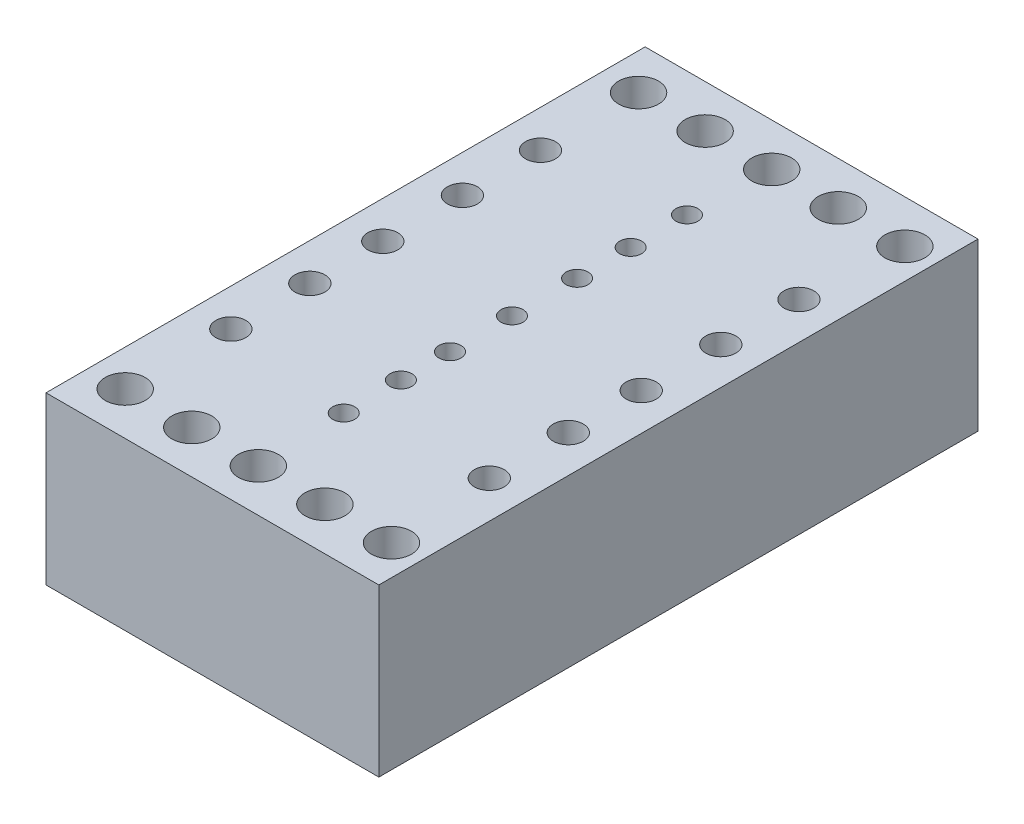
from build123d import *

# Parameters (mm, degrees)
CROQUIS1_W                            = 100
CROQUIS1_H                            = 180
SALIENTE_EXTRUIR1_DEPTH               = 50
TALADRO1_D                            = 12
MATRIZL1_COUNT                        = 5
MATRIZL1_PITCH                        = 20
SIMETR_A1_COPY_1_D                    = 12
SIMETR_A1_COPY_2_D                    = 12
SIMETR_A1_COPY_3_D                    = 12
SIMETR_A1_COPY_4_D                    = 12
TALADRO_DE_MARGEN_PARA_M81_AT_2_COUNT = 2
TALADRO_DE_MARGEN_PARA_M81_AT_2_PITCH = 47.379647221
TALADRO_DE_MARGEN_PARA_M81_AT_3_COUNT = 2
TALADRO_DE_MARGEN_PARA_M81_AT_3_PITCH = 93.023747334
TALADRO_DE_MARGEN_PARA_M81_AT_4_COUNT = 2
TALADRO_DE_MARGEN_PARA_M81_AT_4_PITCH = 23.460534518
TALADRO_DE_MARGEN_PARA_M81_AT_5_COUNT = 2
TALADRO_DE_MARGEN_PARA_M81_AT_5_PITCH = 69.290415903
TALADRO_DE_MARGEN_PARA_M61_D          = 6.6
TALADRO_DE_MARGEN_PARA_M61_DEPTH      = 40
TALADRO_DE_MARGEN_PARA_M61_TIP        = 1.982840043


with BuildPart() as part:
    # Croquis1 → Saliente-Extruir1 (new body)
    with BuildSketch(Plane(origin=(0, 0, 0), x_dir=(1, 0, 0), z_dir=(0, 1, 0))):
        Rectangle(CROQUIS1_W, CROQUIS1_H)
    extrude(amount=SALIENTE_EXTRUIR1_DEPTH)

    # Taladro1 (through all)
    with Locations(Plane(origin=(0, 50, 0), x_dir=(1, 0, 0), z_dir=(0, 1, 0))):
        with Locations((-39.09229064, 77.114510738)):
            taladro1 = Hole(TALADRO1_D / 2)

    # MatrizL1: Taladro1 ×5
    with Locations(*[(i * MATRIZL1_PITCH, 0, 0) for i in range(1, MATRIZL1_COUNT)]):
        add(taladro1, mode=Mode.SUBTRACT)

    # Simetría1: Taladro1 across plane
    add(taladro1.mirror(Plane.XY), mode=Mode.SUBTRACT)

    # Simetría1 copy 1 (through all)
    with Locations(Plane(origin=(20, 50, 0), x_dir=(1, 0, 0), z_dir=(0, 1, 0))):
        with Locations((-39.09229064, -77.114510738)):
            Hole(SIMETR_A1_COPY_1_D / 2)

    # Simetría1 copy 2 (through all)
    with Locations(Plane(origin=(40, 50, 0), x_dir=(1, 0, 0), z_dir=(0, 1, 0))):
        with Locations((-39.09229064, -77.114510738)):
            Hole(SIMETR_A1_COPY_2_D / 2)

    # Simetría1 copy 3 (through all)
    with Locations(Plane(origin=(60, 50, 0), x_dir=(1, 0, 0), z_dir=(0, 1, 0))):
        with Locations((-39.09229064, -77.114510738)):
            Hole(SIMETR_A1_COPY_3_D / 2)

    # Simetría1 copy 4 (through all)
    with Locations(Plane(origin=(80, 50, 0), x_dir=(1, 0, 0), z_dir=(0, 1, 0))):
        with Locations((-39.09229064, -77.114510738)):
            Hole(SIMETR_A1_COPY_4_D / 2)

    # Croquis6 → Taladro de margen para M81 (revolve, cut)
    with BuildSketch(Plane(origin=(-38.819493727, 50, -47.379647221), x_dir=(0, 0, 1), z_dir=(1, 0, 0))):
        Polygon((0, 0), (0, 28.103872786), (4.5, 25.4), (4.5, 0), align=None)
    taladro_de_margen_para_m81 = revolve(axis=Axis((-38.819493727, 56.35, -47.379647221), (0, -1, 0)), mode=Mode.SUBTRACT)

    # Taladro de margen para M81 at 2: Taladro de margen para M81 ×2
    with Locations(*[(0, 0, i * TALADRO_DE_MARGEN_PARA_M81_AT_2_PITCH) for i in range(1, TALADRO_DE_MARGEN_PARA_M81_AT_2_COUNT)]):
        add(taladro_de_margen_para_m81, mode=Mode.SUBTRACT)

    # Taladro de margen para M81 at 3: Taladro de margen para M81 ×2
    with Locations(*[(0, 0, i * TALADRO_DE_MARGEN_PARA_M81_AT_3_PITCH) for i in range(1, TALADRO_DE_MARGEN_PARA_M81_AT_3_COUNT)]):
        add(taladro_de_margen_para_m81, mode=Mode.SUBTRACT)

    # Taladro de margen para M81 at 4: Taladro de margen para M81 ×2
    with Locations(*[(0, 0, i * TALADRO_DE_MARGEN_PARA_M81_AT_4_PITCH) for i in range(1, TALADRO_DE_MARGEN_PARA_M81_AT_4_COUNT)]):
        add(taladro_de_margen_para_m81, mode=Mode.SUBTRACT)

    # Taladro de margen para M81 at 5: Taladro de margen para M81 ×2
    with Locations(*[(0, 0, i * TALADRO_DE_MARGEN_PARA_M81_AT_5_PITCH) for i in range(1, TALADRO_DE_MARGEN_PARA_M81_AT_5_COUNT)]):
        add(taladro_de_margen_para_m81, mode=Mode.SUBTRACT)

    # Simetría2: Taladro de margen para M81 across plane
    add(taladro_de_margen_para_m81.mirror(Plane(origin=(0, 0, 0), x_dir=(0, 0, 1), z_dir=(1, 0, 0))), mode=Mode.SUBTRACT)

    # Simetría2 copy 1 sketch → Simetría2 copy 1 (revolve, cut)
    with BuildSketch(Plane(origin=(38.819493727, 50, 0), x_dir=(0, 0, 1), z_dir=(-1, 0, 0))):
        Polygon((0, 0), (0, -28.103872786), (4.5, -25.4), (4.5, 0), align=None)
    revolve(axis=Axis((38.819493727, 56.35, 0), (0, 1, 0)), mode=Mode.SUBTRACT)

    # Simetría2 copy 2 sketch → Simetría2 copy 2 (revolve, cut)
    with BuildSketch(Plane(origin=(38.819493727, 50, 45.644100113), x_dir=(0, 0, 1), z_dir=(-1, 0, 0))):
        Polygon((0, 0), (0, -28.103872786), (4.5, -25.4), (4.5, 0), align=None)
    revolve(axis=Axis((38.819493727, 56.35, 45.644100113), (0, 1, 0)), mode=Mode.SUBTRACT)

    # Simetría2 copy 3 sketch → Simetría2 copy 3 (revolve, cut)
    with BuildSketch(Plane(origin=(38.819493727, 50, -23.919112702), x_dir=(0, 0, 1), z_dir=(-1, 0, 0))):
        Polygon((0, 0), (0, -28.103872786), (4.5, -25.4), (4.5, 0), align=None)
    revolve(axis=Axis((38.819493727, 56.35, -23.919112702), (0, 1, 0)), mode=Mode.SUBTRACT)

    # Simetría2 copy 4 sketch → Simetría2 copy 4 (revolve, cut)
    with BuildSketch(Plane(origin=(38.819493727, 50, 21.910768682), x_dir=(0, 0, 1), z_dir=(-1, 0, 0))):
        Polygon((0, 0), (0, -28.103872786), (4.5, -25.4), (4.5, 0), align=None)
    revolve(axis=Axis((38.819493727, 56.35, 21.910768682), (0, 1, 0)), mode=Mode.SUBTRACT)

    # Taladro de margen para M61
    with Locations(Plane(origin=(0, 50, 0), x_dir=(1, 0, 0), z_dir=(0, 1, 0))):
        with Locations((0, 52.562788568), (0, 35.649379962), (0, 19.554362094), (0, 0), (0, -18.637205726), (0, -33.368239028), (0, -50.554444547)):
            Hole(TALADRO_DE_MARGEN_PARA_M61_D / 2, depth=TALADRO_DE_MARGEN_PARA_M61_DEPTH)
            with Locations((0, 0, -(TALADRO_DE_MARGEN_PARA_M61_DEPTH + TALADRO_DE_MARGEN_PARA_M61_TIP / 2))):  # 118° drill point
                Cone(0, TALADRO_DE_MARGEN_PARA_M61_D / 2, TALADRO_DE_MARGEN_PARA_M61_TIP, mode=Mode.SUBTRACT)


solid = part.part
